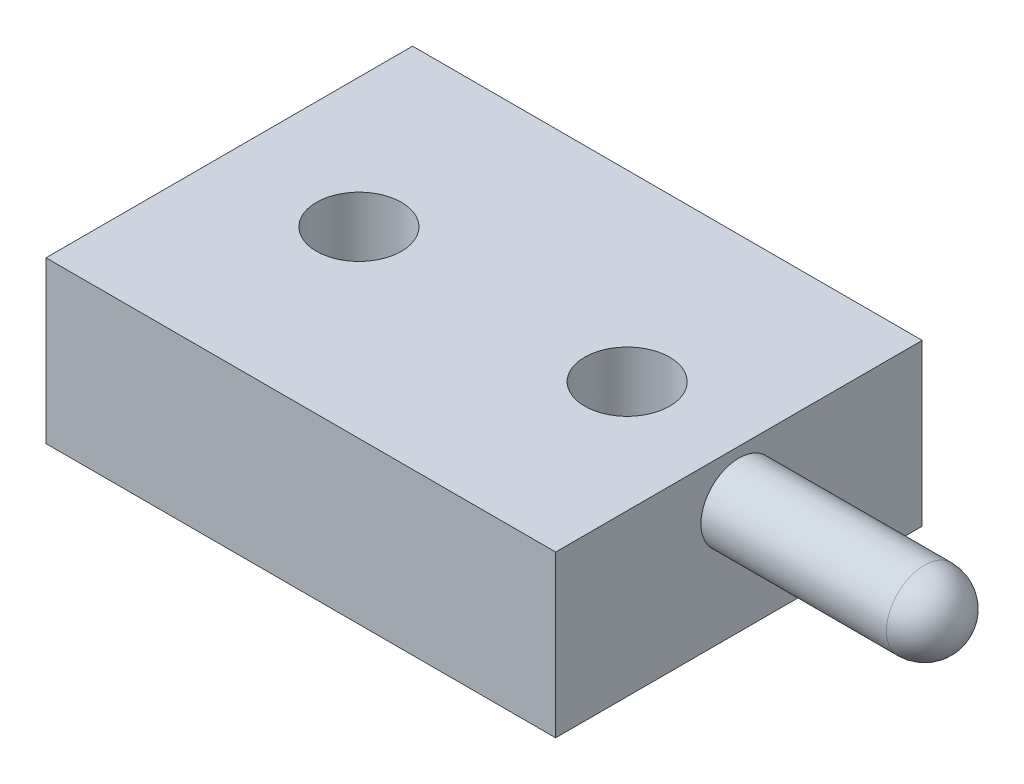
from build123d import *

# Parameters (mm, degrees)
SKETCH1_W                    = 5.7
SKETCH1_H                    = 4.1
BOSS_EXTRUDE1_DEPTH          = 1.8
SKETCH3_R                    = 0.425
BOSS_EXTRUDE3_DEPTH          = 2.5
FILLET2_R                    = 0.425
M1_2X0_25_TAPPED_HOLE1_D     = 0.95
M1_2X0_25_TAPPED_HOLE1_DEPTH = 3.15
M1_2X0_25_TAPPED_HOLE1_TIP   = 0.285408794


with BuildPart() as part:
    # Sketch1 → Boss-Extrude1 (new body)
    with BuildSketch(Plane(origin=(0, 0, 0), x_dir=(1, 0, 0), z_dir=(0, 1, 0))):
        with Locations((2.85, -2.05)):
            Rectangle(SKETCH1_W, SKETCH1_H)
    extrude(amount=-BOSS_EXTRUDE1_DEPTH)

    # Sketch3 → Boss-Extrude3 (add)
    with BuildSketch(Plane(origin=(5.7, 0, 0), x_dir=(0, 0, -1), z_dir=(1, 0, 0))):
        with Locations((-2.05, -0.54)):
            Circle(SKETCH3_R)
    extrude(amount=BOSS_EXTRUDE3_DEPTH)

    # Fillet2
    fillet2_edges = [part.edges().sort_by_distance(p)[0] for p in [
        (8.2, -0.54, 2.475),
    ]]
    fillet(fillet2_edges, radius=FILLET2_R)

    # M1.2x0.25 Tapped Hole1
    with Locations(Plane(origin=(0, -1.8, 0), x_dir=(-1, 0, 0), z_dir=(0, -1, 0))):
        with Locations((-4.45, -2.05), (-1.45, -2.05)):
            Hole(M1_2X0_25_TAPPED_HOLE1_D / 2, depth=M1_2X0_25_TAPPED_HOLE1_DEPTH)
            with Locations((0, 0, -(M1_2X0_25_TAPPED_HOLE1_DEPTH + M1_2X0_25_TAPPED_HOLE1_TIP / 2))):  # 118° drill point
                Cone(0, M1_2X0_25_TAPPED_HOLE1_D / 2, M1_2X0_25_TAPPED_HOLE1_TIP, mode=Mode.SUBTRACT)


solid = part.part
